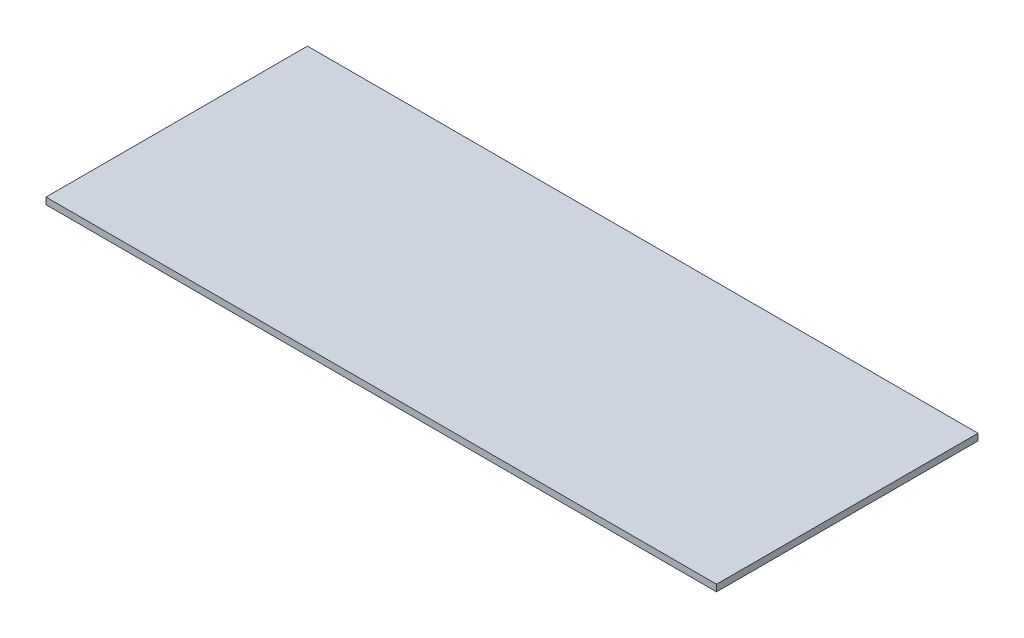
from build123d import *

# Parameters (mm, degrees)
SKETCH1_W           = 405.33723822
SKETCH1_H           = 160
BOSS_EXTRUDE1_DEPTH = 4
SKETCH2_W           = 3.5
SKETCH2_H           = 4
CUT_EXTRUDE2_DEPTH  = 184
SKETCH3_W           = 2
SKETCH3_H           = 4
CUT_EXTRUDE3_DEPTH  = 184
SCALE1_SCALE        = 1.01875
SKETCH4_W           = 5
SKETCH4_H           = 4.075
CUT_EXTRUDE4_DEPTH  = 220
SKETCH5_W           = 0.5
SKETCH5_H           = 4.075
CUT_EXTRUDE5_DEPTH  = 430
SKETCH6_W           = 1
SKETCH6_H           = 4.075
CUT_EXTRUDE6_DEPTH  = 430
SKETCH7_W           = 0.5
SKETCH7_H           = 4.075
CUT_EXTRUDE7_DEPTH  = 430
SKETCH8_W           = 1
SKETCH8_H           = 4.075
CUT_EXTRUDE8_DEPTH  = 430
SKETCH9_W           = 160
SKETCH9_H           = 4.075
BOSS_EXTRUDE2_DEPTH = 6
SKETCH11_W          = 408.334186436
SKETCH11_H          = 4.075
BOSS_EXTRUDE4_DEPTH = 3
SKETCH12_W          = 163
SKETCH12_H          = 4.075
BOSS_EXTRUDE5_DEPTH = 2
SKETCH13_W          = 410.334186436
SKETCH13_H          = 4.075
CUT_EXTRUDE9_DEPTH  = 3


with BuildPart() as part:
    # Sketch1 → Boss-Extrude1 (new body)
    with BuildSketch(Plane(origin=(0, 0, 0), x_dir=(1, 0, 0), z_dir=(0, 1, 0))):
        with Locations((-74.274989913, 53.371553885)):
            Rectangle(SKETCH1_W, SKETCH1_H)
    extrude(amount=BOSS_EXTRUDE1_DEPTH)

    # Sketch2 → Cut-Extrude2 (cut)
    with BuildSketch(Plane.XY.offset(26.628446115)):
        with Locations((126.643629197, 2)):
            Rectangle(SKETCH2_W, SKETCH2_H)
    extrude(amount=-CUT_EXTRUDE2_DEPTH, mode=Mode.SUBTRACT)

    # Sketch3 → Cut-Extrude3 (cut)
    with BuildSketch(Plane.XY.offset(26.628446115)):
        with Locations((123.893629197, 2)):
            Rectangle(SKETCH3_W, SKETCH3_H)
    extrude(amount=-CUT_EXTRUDE3_DEPTH, mode=Mode.SUBTRACT)


with BuildPart() as part_1:
    # Scale1: scaled about (-77.024989913, 2, -53.371553885)
    add(part.part.scale(SCALE1_SCALE).moved(Location((1.444218561, -0.0375, 1.000716635))))

    # Sketch4 → Cut-Extrude4 (cut)
    with BuildSketch(Plane.XY.offset(28.128446115)):
        with Locations((124.142103305, 2)):
            Rectangle(SKETCH4_W, SKETCH4_H)
    extrude(amount=-CUT_EXTRUDE4_DEPTH, mode=Mode.SUBTRACT)

    # Sketch5 → Cut-Extrude5 (cut)
    with BuildSketch(Plane.ZY.offset(280.692083131)):
        with Locations((-134.621553885, 2)):
            Rectangle(SKETCH5_W, SKETCH5_H)
    extrude(amount=-CUT_EXTRUDE5_DEPTH, mode=Mode.SUBTRACT)

    # Sketch6 → Cut-Extrude6 (cut)
    with BuildSketch(Plane.ZY.offset(280.692083131)):
        with Locations((27.628446115, 2)):
            Rectangle(SKETCH6_W, SKETCH6_H)
    extrude(amount=-CUT_EXTRUDE6_DEPTH, mode=Mode.SUBTRACT)

    # Sketch7 → Cut-Extrude7 (cut)
    with BuildSketch(Plane.ZY.offset(280.692083131)):
        with Locations((26.878446115, 2)):
            Rectangle(SKETCH7_W, SKETCH7_H)
    extrude(amount=-CUT_EXTRUDE7_DEPTH, mode=Mode.SUBTRACT)

    # Sketch8 → Cut-Extrude8 (cut)
    with BuildSketch(Plane.ZY.offset(280.692083131)):
        with Locations((-133.871553885, 2)):
            Rectangle(SKETCH8_W, SKETCH8_H)
    extrude(amount=-CUT_EXTRUDE8_DEPTH, mode=Mode.SUBTRACT)

    # Sketch9 → Boss-Extrude2 (add)
    with BuildSketch(Plane.ZY.offset(280.692083131)):
        with Locations((-53.371553885, 2)):
            Rectangle(SKETCH9_W, SKETCH9_H)
    extrude(amount=BOSS_EXTRUDE2_DEPTH)

    # Sketch11 → Boss-Extrude4 (add)
    with BuildSketch(Plane(origin=(0, 0, -133.371553885), x_dir=(-1, 0, 0), z_dir=(0, 0, -1))):
        with Locations((82.524989913, 2)):
            Rectangle(SKETCH11_W, SKETCH11_H)
    extrude(amount=BOSS_EXTRUDE4_DEPTH)

    # Sketch12 → Boss-Extrude5 (add)
    with BuildSketch(Plane(origin=(121.642103305, 0, 0), x_dir=(0, 0, -1), z_dir=(1, 0, 0))):
        with Locations((54.871553885, 2)):
            Rectangle(SKETCH12_W, SKETCH12_H)
    extrude(amount=BOSS_EXTRUDE5_DEPTH)

    # Sketch13 → Cut-Extrude9 (cut)
    with BuildSketch(Plane(origin=(0, 0, -136.371553885), x_dir=(-1, 0, 0), z_dir=(0, 0, -1))):
        with Locations((81.524989913, 2)):
            Rectangle(SKETCH13_W, SKETCH13_H)
    extrude(amount=-CUT_EXTRUDE9_DEPTH, mode=Mode.SUBTRACT)


solid = part_1.part
